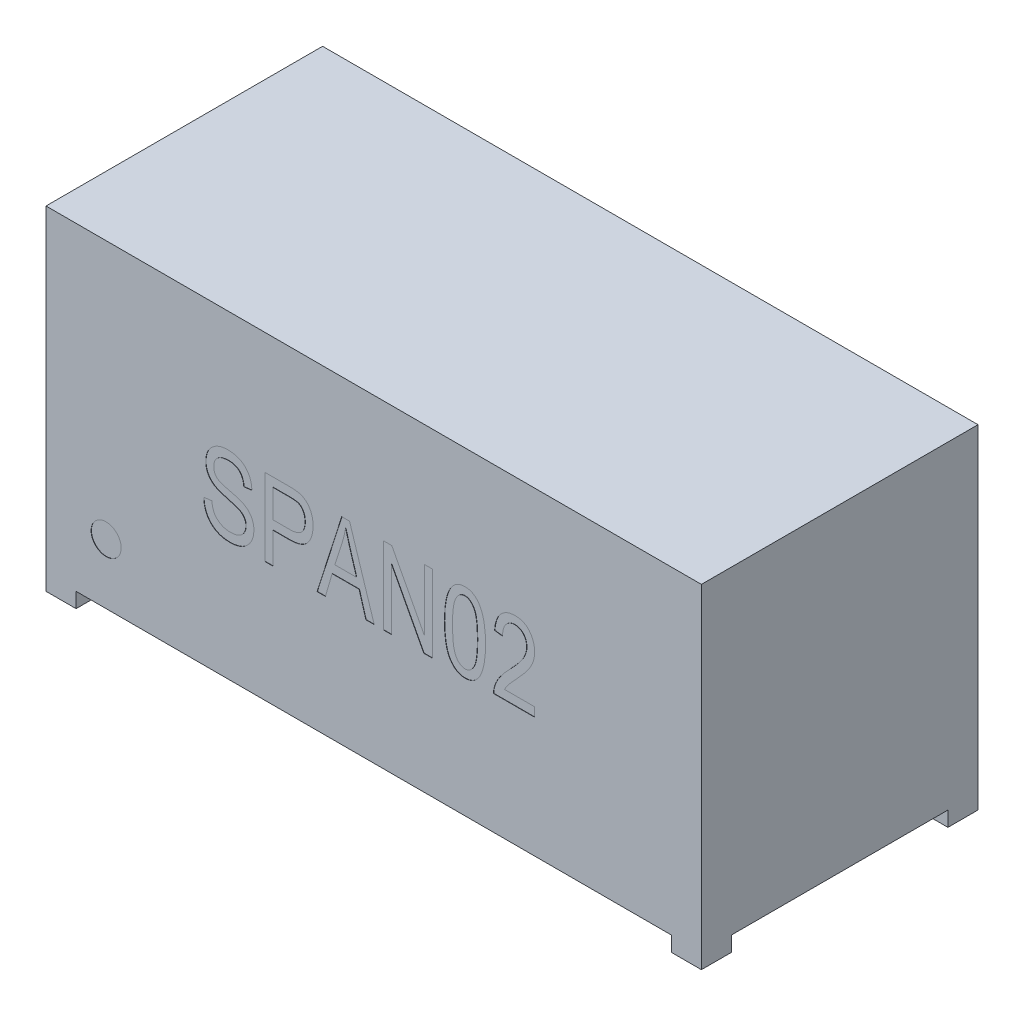
from build123d import *

# Parameters (mm, degrees)
SKETCH1_W           = 21.8
SKETCH1_H           = 9.2
BOSS_EXTRUDE1_DEPTH = 11.1
CUT_EXTRUDE1_DEPTH  = 0.5
SKETCH3_R           = 0.5
CUT_EXTRUDE2_DEPTH  = 0.01
CUT_EXTRUDE3_DEPTH  = 0.01


with BuildPart() as part:
    # Sketch1 → Boss-Extrude1 (new body)
    with BuildSketch(Plane(origin=(0, 0, 0), x_dir=(1, 0, 0), z_dir=(0, 1, 0))):
        Rectangle(SKETCH1_W, SKETCH1_H)
    extrude(amount=BOSS_EXTRUDE1_DEPTH)

    # Sketch2 → Cut-Extrude1 (cut)
    with BuildSketch(Plane.XZ):
        Polygon((-9.9, 4.6), (9.9, 4.6), (9.9, 3.6), (10.9, 3.6), (10.9, -3.6), (9.9, -3.6), (9.9, -4.6), (-9.9, -4.6), (-9.9, -3.6), (-10.9, -3.6), (-10.9, 3.6), (-9.9, 3.6), align=None)
    extrude(amount=-CUT_EXTRUDE1_DEPTH, mode=Mode.SUBTRACT)

    # Sketch3 → Cut-Extrude2 (cut)
    with BuildSketch(Plane.XY.offset(4.6)):
        with Locations((-8.9, 2.5)):
            Circle(SKETCH3_R)
    extrude(amount=-CUT_EXTRUDE2_DEPTH, mode=Mode.SUBTRACT)

    # Sketch5 → Cut-Extrude3 (cut)
    with BuildSketch(Plane.XY.offset(4.6)):
        with BuildLine():
            Line((-5.652844769, 5.333869703), (-5.386006464, 5.367224491))
            add(Edge.make_bspline(
                [(-5.386006464, 5.367224491), (-5.382121142, 5.333253817), (-5.374752601, 5.268828172), (-5.3545714, 5.178605611), (-5.327578981, 5.10022075), (-5.294231611, 5.032094464), (-5.251497332, 4.974346433), (-5.202683769, 4.92241173), (-5.145188397, 4.877103141), (-5.080827807, 4.837548466), (-5.0099886, 4.805624625), (-4.933986342, 4.783566155), (-4.853893891, 4.769448041), (-4.799057803, 4.76772107), (-4.771027558, 4.766838305)],
                knots=[0, 0, 0, 0, 0.000102527, 0.000194444, 0.000276691, 0.000350809, 0.000420967, 0.000491379, 0.000564063, 0.00063986, 0.000717543, 0.000796365, 0.000876733, 0.000960772, 0.000960772, 0.000960772, 0.000960772], degree=3))
            add(Edge.make_bspline(
                [(-4.771027558, 4.766838305), (-4.751032915, 4.767244631), (-4.712174955, 4.768034294), (-4.655593268, 4.773973682), (-4.602299153, 4.782920674), (-4.552793768, 4.79683958), (-4.506156802, 4.813116293), (-4.463701149, 4.834816313), (-4.423971766, 4.859340473), (-4.388122506, 4.887893107), (-4.356511326, 4.919985333), (-4.327857977, 4.953666051), (-4.304560632, 4.990538152), (-4.284915622, 5.0291478), (-4.270509189, 5.070445496), (-4.259335161, 5.113608898), (-4.253105674, 5.159444573), (-4.252337074, 5.190704326), (-4.251943668, 5.206704573)],
                knots=[0, 0, 0, 0, 5.9971e-05, 0.000116548, 0.000170529, 0.00022186, 0.000270661, 0.000318441, 0.00036457, 0.000410557, 0.000455517, 0.000499558, 0.000542928, 0.000586046, 0.000629237, 0.000673857, 0.000719628, 0.000767621, 0.000767621, 0.000767621, 0.000767621], degree=3))
            add(Edge.make_bspline(
                [(-4.251943668, 5.206704573), (-4.252517306, 5.225158441), (-4.253634615, 5.261102093), (-4.263144753, 5.313426518), (-4.279360006, 5.361915975), (-4.301434781, 5.406941654), (-4.329944849, 5.44814197), (-4.36515388, 5.485315321), (-4.406991432, 5.518174675), (-4.446912492, 5.543094685), (-4.485476892, 5.561245412), (-4.521911745, 5.576891113), (-4.565790895, 5.593394732), (-4.617043248, 5.611157852), (-4.67568503, 5.629663194), (-4.741748559, 5.649491058), (-4.81500292, 5.670901387), (-4.866553136, 5.685041574), (-4.893502171, 5.692433675)],
                knots=[0, 0, 0, 0, 5.5332e-05, 0.000107774, 0.000158864, 0.000208277, 0.000257719, 0.000308596, 0.000361258, 0.000416945, 0.000449345, 0.000489036, 0.000535883, 0.000589944, 0.000651753, 0.000720342, 0.00079687, 0.000880702, 0.000880702, 0.000880702, 0.000880702], degree=3))
            add(Edge.make_bspline(
                [(-4.893502171, 5.692433675), (-4.917687113, 5.699257461), (-4.964295224, 5.712407947), (-5.031132502, 5.733453842), (-5.092699101, 5.753882725), (-5.148615527, 5.775678089), (-5.199584027, 5.796377329), (-5.244601211, 5.818590717), (-5.284356479, 5.840341271), (-5.33007686, 5.869196072), (-5.380014612, 5.909552229), (-5.432941708, 5.963477529), (-5.479176945, 6.023188962), (-5.51775196, 6.088681312), (-5.549038097, 6.159150416), (-5.56975482, 6.235111014), (-5.584203943, 6.315029145), (-5.585483348, 6.37005883), (-5.586135193, 6.398095911)],
                knots=[0, 0, 0, 0, 7.5382e-05, 0.000145273, 0.000210209, 0.000269927, 0.000325291, 0.000375171, 0.000420426, 0.000461197, 0.000537218, 0.0006124, 0.000687456, 0.000763162, 0.000839945, 0.000917976, 0.000998858, 0.00108287, 0.00108287, 0.00108287, 0.00108287], degree=3))
            add(Edge.make_bspline(
                [(-5.586135193, 6.398095911), (-5.585560003, 6.423317242), (-5.584429295, 6.472897295), (-5.574776678, 6.545464095), (-5.559476587, 6.614750722), (-5.536645815, 6.680017152), (-5.508713407, 6.742192909), (-5.473339771, 6.800030031), (-5.432436017, 6.854914537), (-5.385078897, 6.9055419), (-5.332918856, 6.9519725), (-5.2753592, 6.991879827), (-5.213614988, 7.02569734), (-5.147673312, 7.054270086), (-5.07692793, 7.075397983), (-5.002051327, 7.090269802), (-4.922943525, 7.100042556), (-4.868689889, 7.101120575), (-4.840864146, 7.101673473)],
                knots=[0, 0, 0, 0, 7.5634e-05, 0.000148681, 0.00021923, 0.000288123, 0.000355754, 0.000423326, 0.000491078, 0.000560776, 0.000630935, 0.000700187, 0.000770398, 0.000841842, 0.000915373, 0.000991417, 0.001070671, 0.001154116, 0.001154116, 0.001154116, 0.001154116], degree=3))
            add(Edge.make_bspline(
                [(-4.840864146, 7.101673473), (-4.802928412, 7.100614397), (-4.728905827, 7.098547861), (-4.621531129, 7.081264593), (-4.521537307, 7.0519846), (-4.429304493, 7.011240975), (-4.345552799, 6.959804953), (-4.271718715, 6.897364602), (-4.207305274, 6.825316391), (-4.153719453, 6.742885109), (-4.11034908, 6.651955432), (-4.078590852, 6.552929734), (-4.057886423, 6.446339715), (-4.053876317, 6.372480413), (-4.051814939, 6.334513346)],
                knots=[0, 0, 0, 0, 0.000113759, 0.000221974, 0.000325208, 0.000425538, 0.000523596, 0.00061902, 0.000714627, 0.000812488, 0.00091296, 0.001015968, 0.0011237, 0.00123766, 0.00123766, 0.00123766, 0.00123766], degree=3))
            Line((-4.051814939, 6.334513346), (-4.318653244, 6.301158558))
            add(Edge.make_bspline(
                [(-4.318653244, 6.301158558), (-4.320610711, 6.321696807), (-4.324427923, 6.361747978), (-4.334974932, 6.419363619), (-4.348455341, 6.47308274), (-4.365356328, 6.522611629), (-4.386593451, 6.567766857), (-4.410238355, 6.60906204), (-4.437779475, 6.646070473), (-4.468506968, 6.678995314), (-4.502758121, 6.707828013), (-4.540074465, 6.73309901), (-4.58077327, 6.754504249), (-4.624926901, 6.771564943), (-4.671960706, 6.78529249), (-4.722447074, 6.794422268), (-4.776102557, 6.800255012), (-4.813052542, 6.801064957), (-4.83200428, 6.80148038)],
                knots=[0, 0, 0, 0, 6.187e-05, 0.000120651, 0.00017551, 0.000227923, 0.000277355, 0.000324998, 0.000370445, 0.000415428, 0.000459804, 0.00050447, 0.000550395, 0.00059743, 0.000646253, 0.000697158, 0.000751143, 0.000807989, 0.000807989, 0.000807989, 0.000807989], degree=3))
            add(Edge.make_bspline(
                [(-4.83200428, 6.80148038), (-4.851307985, 6.801315041), (-4.88861942, 6.800995463), (-4.942886265, 6.794691495), (-4.993701842, 6.78636601), (-5.041135119, 6.773687907), (-5.08477734, 6.757687829), (-5.125235667, 6.738151855), (-5.161960634, 6.714900482), (-5.195151111, 6.688090968), (-5.224217976, 6.658280036), (-5.249788755, 6.626575828), (-5.271656485, 6.592855775), (-5.288700207, 6.556611119), (-5.302311684, 6.518380802), (-5.312315272, 6.478087783), (-5.318012623, 6.43560916), (-5.318863106, 6.406625006), (-5.319296888, 6.391841888)],
                knots=[0, 0, 0, 0, 5.7871e-05, 0.000111856, 0.000163694, 0.000212238, 0.000258902, 0.000302956, 0.000346765, 0.000389008, 0.000430653, 0.000471431, 0.000511043, 0.000550905, 0.000591291, 0.000632625, 0.000675227, 0.000719575, 0.000719575, 0.000719575, 0.000719575], degree=3))
            add(Edge.make_bspline(
                [(-5.319296888, 6.391841888), (-5.318412722, 6.365343033), (-5.316731521, 6.31495669), (-5.301014027, 6.243976734), (-5.274852248, 6.181762164), (-5.248318377, 6.147804673), (-5.235388749, 6.131257606)],
                knots=[0, 0, 0, 0, 7.9389e-05, 0.000150954, 0.000216995, 0.00027976, 0.00027976, 0.00027976, 0.00027976], degree=3))
            add(Edge.make_bspline(
                [(-5.235388749, 6.131257606), (-5.227449908, 6.123341134), (-5.210207158, 6.106146968), (-5.176998212, 6.084484132), (-5.137468161, 6.061694113), (-5.089563053, 6.041024354), (-5.035028793, 6.019351532), (-4.972488477, 5.999481694), (-4.902735307, 5.978922984), (-4.853253271, 5.966714341), (-4.827313763, 5.960314317)],
                knots=[0, 0, 0, 0, 3.3554e-05, 7.2877e-05, 0.000118386, 0.000170404, 0.00022915, 0.000294415, 0.000367149, 0.000447289, 0.000447289, 0.000447289, 0.000447289], degree=3))
            add(Edge.make_bspline(
                [(-4.827313763, 5.960314317), (-4.80175447, 5.954148163), (-4.752642327, 5.942299907), (-4.682211633, 5.923820993), (-4.61750847, 5.906740372), (-4.558628943, 5.890381936), (-4.505981893, 5.873456192), (-4.459102353, 5.857764101), (-4.417723737, 5.843751067), (-4.39277481, 5.832950941), (-4.381193472, 5.827937502)],
                knots=[0, 0, 0, 0, 7.8876e-05, 0.00015156, 0.000218434, 0.000279642, 0.000334859, 0.000384301, 0.000427983, 0.000465828, 0.000465828, 0.000465828, 0.000465828], degree=3))
            add(Edge.make_bspline(
                [(-4.381193472, 5.827937502), (-4.349950161, 5.812825649), (-4.289374953, 5.78352646), (-4.208625331, 5.726095227), (-4.139465686, 5.660837442), (-4.083189156, 5.586305986), (-4.03877293, 5.504142749), (-4.007660866, 5.414022798), (-3.988406937, 5.316617625), (-3.9862263, 5.249185169), (-3.985105363, 5.214522102)],
                knots=[0, 0, 0, 0, 0.000103964, 0.000201567, 0.000295934, 0.000388183, 0.000480522, 0.000574969, 0.000673194, 0.000777095, 0.000777095, 0.000777095, 0.000777095], degree=3))
            add(Edge.make_bspline(
                [(-3.985105363, 5.214522102), (-3.986238874, 5.17968676), (-3.988478586, 5.110855332), (-4.008357287, 5.010174453), (-4.040837048, 4.914228664), (-4.086267424, 4.82457547), (-4.14186434, 4.742033948), (-4.207289831, 4.668813523), (-4.28283582, 4.606704986), (-4.367441842, 4.555420106), (-4.461113921, 4.514728132), (-4.564254831, 4.487307973), (-4.676083468, 4.46955582), (-4.753756178, 4.467637908), (-4.793958975, 4.466645212)],
                knots=[0, 0, 0, 0, 0.000104421, 0.000206327, 0.000306532, 0.000407453, 0.000506904, 0.00060433, 0.000700954, 0.000799185, 0.000900261, 0.001006216, 0.001118549, 0.001239075, 0.001239075, 0.001239075, 0.001239075], degree=3))
            add(Edge.make_bspline(
                [(-4.793958975, 4.466645212), (-4.825609605, 4.467308893), (-4.887371673, 4.46860398), (-4.977381044, 4.479755683), (-5.062379784, 4.497900129), (-5.142557213, 4.523470499), (-5.218034087, 4.556430996), (-5.288727732, 4.596632045), (-5.354287263, 4.644353057), (-5.414196466, 4.69925965), (-5.468374675, 4.760179316), (-5.516114264, 4.826603376), (-5.556496384, 4.898691565), (-5.589566076, 4.975856044), (-5.616462856, 5.057958503), (-5.636131004, 5.145184044), (-5.648703406, 5.237805407), (-5.651442598, 5.301344535), (-5.652844769, 5.333869703)],
                knots=[0, 0, 0, 0, 9.4923e-05, 0.000185229, 0.000271607, 0.000355335, 0.000437251, 0.000518249, 0.00059883, 0.000679988, 0.000761573, 0.000842998, 0.000924903, 0.001008939, 0.001094476, 0.001183736, 0.001276827, 0.001374454, 0.001374454, 0.001374454, 0.001374454], degree=3))
        make_face()
        with BuildLine():
            Line((-3.618202694, 4.5), (-3.618202694, 7.068318685))
            Line((-3.618202694, 7.068318685), (-2.827068813, 7.068318685))
            add(Edge.make_bspline(
                [(-2.827068813, 7.068318685), (-2.804480059, 7.068339881), (-2.761022672, 7.06838066), (-2.698143749, 7.065304346), (-2.639684537, 7.06219581), (-2.585850098, 7.056197701), (-2.536599701, 7.049647983), (-2.491983646, 7.04146332), (-2.451993025, 7.031119295), (-2.427117559, 7.022762425), (-2.415345647, 7.018807671)],
                knots=[0, 0, 0, 0, 6.7754e-05, 0.000130348, 0.000188833, 0.000243337, 0.000292793, 0.00033787, 0.000379332, 0.00041658, 0.00041658, 0.00041658, 0.00041658], degree=3))
            add(Edge.make_bspline(
                [(-2.415345647, 7.018807671), (-2.400439404, 7.013038143), (-2.370662241, 7.001512758), (-2.328719401, 6.978759296), (-2.288708803, 6.953125235), (-2.251083894, 6.923942741), (-2.216065346, 6.890762027), (-2.183105008, 6.85431214), (-2.152857719, 6.813843763), (-2.124989019, 6.770218828), (-2.09903895, 6.723877459), (-2.077612929, 6.674252977), (-2.058365991, 6.622391635), (-2.043722007, 6.567686012), (-2.031346447, 6.510523071), (-2.023464193, 6.450729566), (-2.017846195, 6.388300908), (-2.01740072, 6.345818972), (-2.017172864, 6.324089975)],
                knots=[0, 0, 0, 0, 4.7908e-05, 9.5702e-05, 0.00014283, 0.000190368, 0.000238298, 0.000287379, 0.00033762, 0.000389664, 0.000442613, 0.000496747, 0.000551648, 0.00060842, 0.000666478, 0.00072699, 0.000789227, 0.000854392, 0.000854392, 0.000854392, 0.000854392], degree=3))
            add(Edge.make_bspline(
                [(-2.017172864, 6.324089975), (-2.017614041, 6.295578913), (-2.018476879, 6.239817963), (-2.02694862, 6.158260765), (-2.041028381, 6.080932955), (-2.060238714, 6.007463049), (-2.085187877, 5.937961997), (-2.116081925, 5.872612436), (-2.152324276, 5.81118033), (-2.193700134, 5.753551054), (-2.242457613, 5.70109451), (-2.300000966, 5.656218321), (-2.365106167, 5.617837394), (-2.438585958, 5.58733056), (-2.519690799, 5.562689286), (-2.609155979, 5.545890991), (-2.706635821, 5.536161667), (-2.774233779, 5.534737992), (-2.809349082, 5.533998432)],
                knots=[0, 0, 0, 0, 8.5511e-05, 0.00016724, 0.000245646, 0.000321115, 0.000394806, 0.000466845, 0.000537635, 0.000608522, 0.000679313, 0.000751673, 0.000826665, 0.000905363, 0.000989776, 0.00108054, 0.001177982, 0.001283321, 0.001283321, 0.001283321, 0.001283321], degree=3))
            Line((-2.809349082, 5.533998432), (-3.351364389, 5.533998432))
            Line((-3.351364389, 5.533998432), (-3.351364389, 4.5))
            Line((-3.351364389, 4.5), (-3.618202694, 4.5))
        make_face()
        with BuildLine():
            Line((-3.351364389, 5.834191525), (-2.792671688, 5.834191525))
            add(Edge.make_bspline(
                [(-2.792671688, 5.834191525), (-2.771469589, 5.834667868), (-2.730390297, 5.835590788), (-2.670765419, 5.840513452), (-2.615535453, 5.84990208), (-2.564718286, 5.862759223), (-2.518455384, 5.879524977), (-2.47651596, 5.899685152), (-2.439139469, 5.923950215), (-2.405737118, 5.95168508), (-2.377268163, 5.983909914), (-2.351659067, 6.019012337), (-2.330890716, 6.05864983), (-2.313918606, 6.101881843), (-2.30013256, 6.148567425), (-2.291036429, 6.199068984), (-2.28522227, 6.253249009), (-2.284422891, 6.290719287), (-2.284011169, 6.310018424)],
                knots=[0, 0, 0, 0, 6.3617e-05, 0.000123258, 0.000179293, 0.000231498, 0.000280299, 0.000326683, 0.000370774, 0.000413681, 0.000456486, 0.000499441, 0.00054374, 0.000590291, 0.000638613, 0.000689518, 0.000744021, 0.000801909, 0.000801909, 0.000801909, 0.000801909], degree=3))
            add(Edge.make_bspline(
                [(-2.284011169, 6.310018424), (-2.284603921, 6.335086576), (-2.28575093, 6.383594891), (-2.297615264, 6.453369261), (-2.315968161, 6.517734489), (-2.342828814, 6.575395867), (-2.374242035, 6.625959255), (-2.408639302, 6.669212578), (-2.447056732, 6.703194408), (-2.482810661, 6.724374411), (-2.514210438, 6.737732194), (-2.542191917, 6.745975389), (-2.574502496, 6.752450205), (-2.611025557, 6.758120138), (-2.651689954, 6.762901005), (-2.696573284, 6.76571777), (-2.745742736, 6.768029233), (-2.779986565, 6.768092517), (-2.797883374, 6.768125592)],
                knots=[0, 0, 0, 0, 7.5137e-05, 0.000145394, 0.000211687, 0.000275351, 0.000335511, 0.000389965, 0.000440562, 0.00048847, 0.000513927, 0.00054278, 0.000575795, 0.000612725, 0.000653646, 0.000698575, 0.000747609, 0.000801292, 0.000801292, 0.000801292, 0.000801292], degree=3))
            Line((-2.797883374, 6.768125592), (-3.351364389, 6.768125592))
            Line((-3.351364389, 6.768125592), (-3.351364389, 5.834191525))
        make_face(mode=Mode.SUBTRACT)
        Polygon((-1.883753712, 4.5), (-1.063434392, 7.068318685), (-0.803371278, 7.068318685), (0.017469211, 4.5), (-0.259792465, 4.5), (-0.484416117, 5.267160127), (-1.381868384, 5.267160127), (-1.605970867, 4.5), align=None)
        with BuildLine():
            Line((-1.294312065, 5.56735322), (-0.572493604, 5.56735322))
            Line((-0.572493604, 5.56735322), (-0.787215052, 6.273015456))
            add(Edge.make_bspline(
                [(-0.787215052, 6.273015456), (-0.795247836, 6.299409004), (-0.810930674, 6.35093856), (-0.833139003, 6.426393688), (-0.854453952, 6.497961468), (-0.872661026, 6.566141121), (-0.890765789, 6.630045564), (-0.906379915, 6.690385948), (-0.920396195, 6.74686281), (-0.92900621, 6.783405159), (-0.93314225, 6.800959211)],
                knots=[0, 0, 0, 0, 8.2766e-05, 0.000161588, 0.000235969, 0.000306773, 0.000373281, 0.000435221, 0.000493746, 0.000547849, 0.000547849, 0.000547849, 0.000547849], degree=3))
            add(Edge.make_bspline(
                [(-0.93314225, 6.800959211), (-0.94065095, 6.760071044), (-0.955658373, 6.678349024), (-0.983789198, 6.556608927), (-1.015085593, 6.435088515), (-1.039996371, 6.354917194), (-1.052489852, 6.314708941)],
                knots=[0, 0, 0, 0, 0.0001247, 0.000249234, 0.000374759, 0.000501054, 0.000501054, 0.000501054, 0.000501054], degree=3))
            Line((-1.052489852, 6.314708941), (-1.294312065, 5.56735322))
        make_face(mode=Mode.SUBTRACT)
        Polygon((0.317662304, 4.5), (0.317662304, 7.068318685), (0.601699171, 7.068318685), (1.685208617, 5.021168564), (1.685208617, 7.068318685), (1.952046922, 7.068318685), (1.952046922, 4.5), (1.666446548, 4.5), (0.584500609, 6.544544278), (0.584500609, 4.5), align=None)
        with BuildLine():
            add(Edge.make_bspline(
                [(2.352304379, 5.783117005), (2.352728109, 5.835593249), (2.353550891, 5.937489493), (2.36205417, 6.085278459), (2.375466356, 6.223346186), (2.393705119, 6.351507542), (2.418389138, 6.469781768), (2.447457035, 6.578358617), (2.48315821, 6.676892803), (2.523342087, 6.765806836), (2.569423752, 6.844604245), (2.620226839, 6.913555804), (2.677258353, 6.97154243), (2.738945717, 7.019760568), (2.806516122, 7.056494348), (2.879007826, 7.082894169), (2.956688808, 7.098824897), (3.010291404, 7.100711084), (3.037641041, 7.101673473)],
                knots=[0, 0, 0, 0, 0.000157414, 0.000305661, 0.000443915, 0.000573488, 0.000693792, 0.000806192, 0.000910384, 0.001007864, 0.001098499, 0.001183762, 0.001264103, 0.001341764, 0.001417798, 0.001493805, 0.001572506, 0.001654496, 0.001654496, 0.001654496, 0.001654496], degree=3))
            add(Edge.make_bspline(
                [(3.037641041, 7.101673473), (3.062013936, 7.100891606), (3.109876724, 7.099356199), (3.179720638, 7.086694366), (3.245413351, 7.065153625), (3.307004485, 7.035218412), (3.364306947, 6.996569358), (3.417884523, 6.949837829), (3.467150089, 6.894081619), (3.495677561, 6.852195597), (3.510340929, 6.83066582)],
                knots=[0, 0, 0, 0, 7.3083e-05, 0.000143518, 0.000212078, 0.000279906, 0.000348277, 0.000418828, 0.000492664, 0.000570758, 0.000570758, 0.000570758, 0.000570758], degree=3))
            add(Edge.make_bspline(
                [(3.510340929, 6.83066582), (3.527314195, 6.801638804), (3.562611893, 6.741274063), (3.604759057, 6.640134264), (3.640285228, 6.5271696), (3.670239451, 6.402020548), (3.691606484, 6.264429059), (3.70851718, 6.114930347), (3.718304262, 5.953148634), (3.719322852, 5.84115352), (3.719850692, 5.783117005)],
                knots=[0, 0, 0, 0, 0.000100785, 0.000209593, 0.00032777, 0.000455823, 0.000595224, 0.000745209, 0.000907074, 0.001081172, 0.001081172, 0.001081172, 0.001081172], degree=3))
            add(Edge.make_bspline(
                [(3.719850692, 5.783117005), (3.719432098, 5.730987541), (3.718619448, 5.629784386), (3.710031074, 5.482699253), (3.696797586, 5.34530245), (3.678311098, 5.217531984), (3.653856001, 5.099548126), (3.624401874, 4.991000803), (3.589814884, 4.891938077), (3.549074777, 4.803014564), (3.503671472, 4.723757423), (3.452006569, 4.655504585), (3.396349517, 4.596481541), (3.333861421, 4.549307801), (3.266752062, 4.511534271), (3.193771802, 4.485579404), (3.115831878, 4.469425394), (3.062043469, 4.467586418), (3.03451403, 4.466645212)],
                knots=[0, 0, 0, 0, 0.000156372, 0.000303578, 0.000441832, 0.000570374, 0.000690678, 0.000803078, 0.000907585, 0.001005064, 0.00109615, 0.001180996, 0.001261347, 0.001338691, 0.001414976, 0.001491473, 0.001570174, 0.001652684, 0.001652684, 0.001652684, 0.001652684], degree=3))
            add(Edge.make_bspline(
                [(3.03451403, 4.466645212), (3.009959899, 4.46756682), (2.961683717, 4.469378805), (2.890849855, 4.483155649), (2.823809469, 4.50690948), (2.760208428, 4.539543541), (2.699962179, 4.581265902), (2.643806823, 4.6329554), (2.590385629, 4.69325139), (2.540341095, 4.763265493), (2.495118244, 4.844797427), (2.456890413, 4.939787791), (2.424321473, 5.047782848), (2.398476444, 5.169218599), (2.376722695, 5.303598703), (2.3630513, 5.451597166), (2.353989737, 5.612928397), (2.352880839, 5.724905697), (2.352304379, 5.783117005)],
                knots=[0, 0, 0, 0, 7.3634e-05, 0.000144773, 0.000215485, 0.000286343, 0.000358628, 0.000434633, 0.000514746, 0.000599927, 0.00069231, 0.000793738, 0.000906506, 0.001030304, 0.001165938, 0.001314668, 0.001475952, 0.001650572, 0.001650572, 0.001650572, 0.001650572], degree=3))
        make_face()
        with BuildLine():
            add(Edge.make_bspline(
                [(2.619142684, 5.784159342), (2.619607968, 5.73412358), (2.620496799, 5.638540423), (2.625381443, 5.501377217), (2.634613895, 5.377244182), (2.647436828, 5.265750187), (2.663694198, 5.167355784), (2.683759533, 5.08151924), (2.707669348, 5.00858958), (2.735799251, 4.947528424), (2.766993365, 4.896839816), (2.800312701, 4.853647131), (2.834763853, 4.816187567), (2.872423649, 4.786264972), (2.911521597, 4.762070448), (2.953568507, 4.746283463), (2.997081227, 4.734888532), (3.027141805, 4.733955156), (3.042331558, 4.733483517)],
                knots=[0, 0, 0, 0, 0.000150111, 0.000286757, 0.000411669, 0.00052344, 0.000623342, 0.000710691, 0.000787656, 0.000853176, 0.000911902, 0.000965794, 0.001016672, 0.001064124, 0.001109708, 0.001153936, 0.001198431, 0.001243881, 0.001243881, 0.001243881, 0.001243881], degree=3))
            add(Edge.make_bspline(
                [(3.042331558, 4.733483517), (3.05665019, 4.733978031), (3.085160865, 4.734962687), (3.126720445, 4.746241282), (3.166785793, 4.762785723), (3.204683557, 4.786729749), (3.240359315, 4.817526428), (3.274296588, 4.854916386), (3.306545908, 4.898940726), (3.337471072, 4.950389435), (3.365302104, 5.011760799), (3.388974527, 5.085037013), (3.408893579, 5.170846022), (3.425370203, 5.269189217), (3.437307001, 5.380242392), (3.44686362, 5.50362571), (3.451621443, 5.639759041), (3.452535444, 5.734645651), (3.453012387, 5.784159342)],
                knots=[0, 0, 0, 0, 4.285e-05, 8.5321e-05, 0.000128298, 0.000172548, 0.000219128, 0.000269296, 0.000323707, 0.000382609, 0.000449075, 0.000525382, 0.000613237, 0.00071314, 0.000824333, 0.000948206, 0.001084331, 0.001232878, 0.001232878, 0.001232878, 0.001232878], degree=3))
            add(Edge.make_bspline(
                [(3.453012387, 5.784159342), (3.452537566, 5.834194509), (3.451627222, 5.93012371), (3.446847695, 6.067468376), (3.437447723, 6.191931345), (3.424851657, 6.303286935), (3.408282664, 6.401788776), (3.388614731, 6.487565398), (3.364313975, 6.560348312), (3.336583555, 6.621287674), (3.304754526, 6.671525359), (3.272256445, 6.715373632), (3.236643252, 6.75190639), (3.199209939, 6.782326949), (3.15941133, 6.806031756), (3.117072782, 6.822970761), (3.072523471, 6.833163843), (3.042036312, 6.83427572), (3.026696501, 6.834835168)],
                knots=[0, 0, 0, 0, 0.000150111, 0.000287798, 0.000412191, 0.000524479, 0.000623868, 0.000711723, 0.000788195, 0.000853715, 0.000911997, 0.000966304, 0.001017165, 0.001064618, 0.001110649, 0.001155554, 0.001200947, 0.001246916, 0.001246916, 0.001246916, 0.001246916], degree=3))
            add(Edge.make_bspline(
                [(3.026696501, 6.834835168), (3.012375537, 6.834353718), (2.984029006, 6.833400748), (2.942814969, 6.822074617), (2.903276196, 6.805513914), (2.865656052, 6.781463381), (2.830429241, 6.750232688), (2.796216758, 6.713074307), (2.764674711, 6.66865293), (2.733636142, 6.61767521), (2.706293164, 6.556139704), (2.682584016, 6.482990959), (2.663515024, 6.397028015), (2.646664491, 6.298980739), (2.634880232, 6.188069481), (2.625281523, 6.064695077), (2.620536481, 5.928559039), (2.619620606, 5.833672826), (2.619142684, 5.784159342)],
                knots=[0, 0, 0, 0, 4.285e-05, 8.4816e-05, 0.000127313, 0.000171122, 0.000218042, 0.00026821, 0.000322313, 0.000381215, 0.000446991, 0.000523793, 0.000611529, 0.000710918, 0.000822111, 0.000945984, 0.001082109, 0.001230656, 0.001230656, 0.001230656, 0.001230656], degree=3))
        make_face(mode=Mode.SUBTRACT)
        with BuildLine():
            Line((5.354235309, 4.800193093), (5.354235309, 4.5))
            Line((5.354235309, 4.5), (3.986688997, 4.5))
            add(Edge.make_bspline(
                [(3.986688997, 4.5), (3.986625678, 4.515641316), (3.986497394, 4.547330878), (3.990762428, 4.595644413), (3.999525306, 4.645127646), (4.010714607, 4.696440691), (4.026579816, 4.748908673), (4.046001774, 4.80278653), (4.068917977, 4.857940127), (4.095750761, 4.914696105), (4.127106218, 4.973598874), (4.164943168, 5.034401995), (4.208427205, 5.098196141), (4.257615837, 5.164592401), (4.313471078, 5.232961087), (4.374335085, 5.304317123), (4.441076469, 5.378511889), (4.488596477, 5.427822417), (4.513069247, 5.453217304)],
                knots=[0, 0, 0, 0, 4.6908e-05, 9.5037e-05, 0.000145245, 0.00019759, 0.000252501, 0.00030954, 0.000369354, 0.000431601, 0.00049782, 0.000569418, 0.00064632, 0.000729395, 0.000817219, 0.000911113, 0.001010748, 0.001116545, 0.001116545, 0.001116545, 0.001116545], degree=3))
            add(Edge.make_bspline(
                [(4.513069247, 5.453217304), (4.541509348, 5.482633722), (4.596268551, 5.539272747), (4.673336901, 5.622903738), (4.743361236, 5.700637705), (4.804942517, 5.773880307), (4.859174036, 5.841634002), (4.906601422, 5.903801916), (4.94495812, 5.961794911), (4.986372448, 6.030032), (5.025855126, 6.111267173), (5.06076005, 6.205959621), (5.083313099, 6.297499039), (5.086062204, 6.357849027), (5.087397004, 6.387151371)],
                knots=[0, 0, 0, 0, 0.000122745, 0.000236336, 0.000341162, 0.000436586, 0.00052335, 0.000601526, 0.000671052, 0.00073183, 0.000840913, 0.00094132, 0.001034369, 0.001122187, 0.001122187, 0.001122187, 0.001122187], degree=3))
            add(Edge.make_bspline(
                [(5.087397004, 6.387151371), (5.087210885, 6.403328598), (5.086847373, 6.434924414), (5.080670005, 6.481066725), (5.071860265, 6.524955208), (5.060228796, 6.566907056), (5.043736715, 6.606233199), (5.023976421, 6.643206484), (5.000830041, 6.677994368), (4.974416505, 6.710085977), (4.945288385, 6.739036619), (4.914591433, 6.765045135), (4.881527093, 6.78609522), (4.847454318, 6.804419747), (4.811221722, 6.817700242), (4.773592269, 6.827823413), (4.734217814, 6.833531317), (4.707482285, 6.834396242), (4.693914738, 6.834835168)],
                knots=[0, 0, 0, 0, 4.8494e-05, 9.4714e-05, 0.000139379, 0.000182762, 0.000225057, 0.000267026, 0.000308366, 0.000350206, 0.000391481, 0.000431451, 0.000470626, 0.000508856, 0.000547285, 0.000586094, 0.0006256, 0.000666304, 0.000666304, 0.000666304, 0.000666304], degree=3))
            add(Edge.make_bspline(
                [(4.693914738, 6.834835168), (4.679286262, 6.83452828), (4.650730805, 6.833929222), (4.609109364, 6.826484539), (4.569228379, 6.816525026), (4.531290223, 6.801078689), (4.495572396, 6.781292871), (4.461560366, 6.757476875), (4.429919874, 6.729180528), (4.400013547, 6.697004194), (4.373796842, 6.660312976), (4.349726062, 6.620609066), (4.330771336, 6.57621061), (4.31465435, 6.528486634), (4.302032214, 6.476880835), (4.293595324, 6.421587839), (4.287408135, 6.362621128), (4.287060663, 6.322022875), (4.28688209, 6.301158558)],
                knots=[0, 0, 0, 0, 4.3828e-05, 8.5554e-05, 0.000126511, 0.000166965, 0.000208018, 0.000248793, 0.000291251, 0.000335144, 0.000380281, 0.000426313, 0.00047415, 0.000524746, 0.00057733, 0.00063328, 0.00069245, 0.00075501, 0.00075501, 0.00075501, 0.00075501], degree=3))
            Line((4.28688209, 6.301158558), (4.020043785, 6.334513346))
            add(Edge.make_bspline(
                [(4.020043785, 6.334513346), (4.022793683, 6.36547781), (4.028128611, 6.425550276), (4.042125979, 6.512514495), (4.061549845, 6.593201711), (4.084607187, 6.668416877), (4.11361598, 6.737226535), (4.14604873, 6.800882939), (4.184489308, 6.858002317), (4.227356894, 6.909290819), (4.274292489, 6.954794179), (4.32503156, 6.99407166), (4.379505205, 7.027181835), (4.437091329, 7.055022153), (4.498980269, 7.075812062), (4.564061735, 7.090900911), (4.632865059, 7.099840267), (4.679816967, 7.101053378), (4.703816941, 7.101673473)],
                knots=[0, 0, 0, 0, 9.3241e-05, 0.000180892, 0.000263943, 0.000342073, 0.0004166, 0.000487697, 0.000556068, 0.000622663, 0.000687901, 0.000751803, 0.000814728, 0.000878834, 0.000943276, 0.001010152, 0.001078998, 0.001150987, 0.001150987, 0.001150987, 0.001150987], degree=3))
            add(Edge.make_bspline(
                [(4.703816941, 7.101673473), (4.729729968, 7.100912824), (4.780186935, 7.099431715), (4.853640388, 7.089672381), (4.922149159, 7.072457574), (4.986019253, 7.048502903), (5.044483609, 7.016967239), (5.098493204, 6.979139347), (5.147146681, 6.933869301), (5.190443835, 6.882358376), (5.228707631, 6.826746148), (5.262095294, 6.768594883), (5.291056411, 6.708868139), (5.313690342, 6.646901322), (5.332592084, 6.583526075), (5.344466572, 6.517781712), (5.352826125, 6.450426803), (5.353762928, 6.404897655), (5.354235309, 6.381939686)],
                knots=[0, 0, 0, 0, 7.774e-05, 0.000151372, 0.000221778, 0.000289243, 0.000355462, 0.000420531, 0.000486547, 0.000554212, 0.000622014, 0.000688791, 0.000755227, 0.000820862, 0.000886508, 0.000953356, 0.00102104, 0.001089883, 0.001089883, 0.001089883, 0.001089883], degree=3))
            add(Edge.make_bspline(
                [(5.354235309, 6.381939686), (5.353790237, 6.36125556), (5.35290589, 6.32015679), (5.347153142, 6.258835093), (5.336998473, 6.19833782), (5.323813084, 6.13808327), (5.305102927, 6.079004398), (5.283922031, 6.020162888), (5.258231247, 5.962222552), (5.227902637, 5.904052406), (5.192391775, 5.843593951), (5.149838017, 5.779743753), (5.101030526, 5.710795069), (5.043986816, 5.637976415), (4.98147094, 5.559193728), (4.910721051, 5.476432105), (4.833117522, 5.388961733), (4.778443577, 5.329610279), (4.750200943, 5.298951409)],
                knots=[0, 0, 0, 0, 6.2054e-05, 0.0001233, 0.000184561, 0.000246008, 0.000308158, 0.000370317, 0.000433553, 0.000498121, 0.000567036, 0.000643791, 0.000728246, 0.000820397, 0.000921243, 0.001029949, 0.00114698, 0.001272031, 0.001272031, 0.001272031, 0.001272031], degree=3))
            add(Edge.make_bspline(
                [(4.750200943, 5.298951409), (4.732271554, 5.279875412), (4.698007051, 5.243419649), (4.649484409, 5.190667705), (4.605942154, 5.142679917), (4.566432291, 5.100131863), (4.532908098, 5.061592655), (4.503843024, 5.028080355), (4.480094627, 4.999181893), (4.444503236, 4.953751703), (4.399613269, 4.889740979), (4.368599779, 4.829395569), (4.353591666, 4.800193093)],
                knots=[0, 0, 0, 0, 7.8538e-05, 0.000150092, 0.000215018, 0.000272934, 0.000324266, 0.000368245, 0.000406014, 0.000436457, 0.000541407, 0.000639819, 0.000639819, 0.000639819, 0.000639819], degree=3))
            Line((4.353591666, 4.800193093), (5.354235309, 4.800193093))
        make_face()
    extrude(amount=-CUT_EXTRUDE3_DEPTH, mode=Mode.SUBTRACT)


solid = part.part
